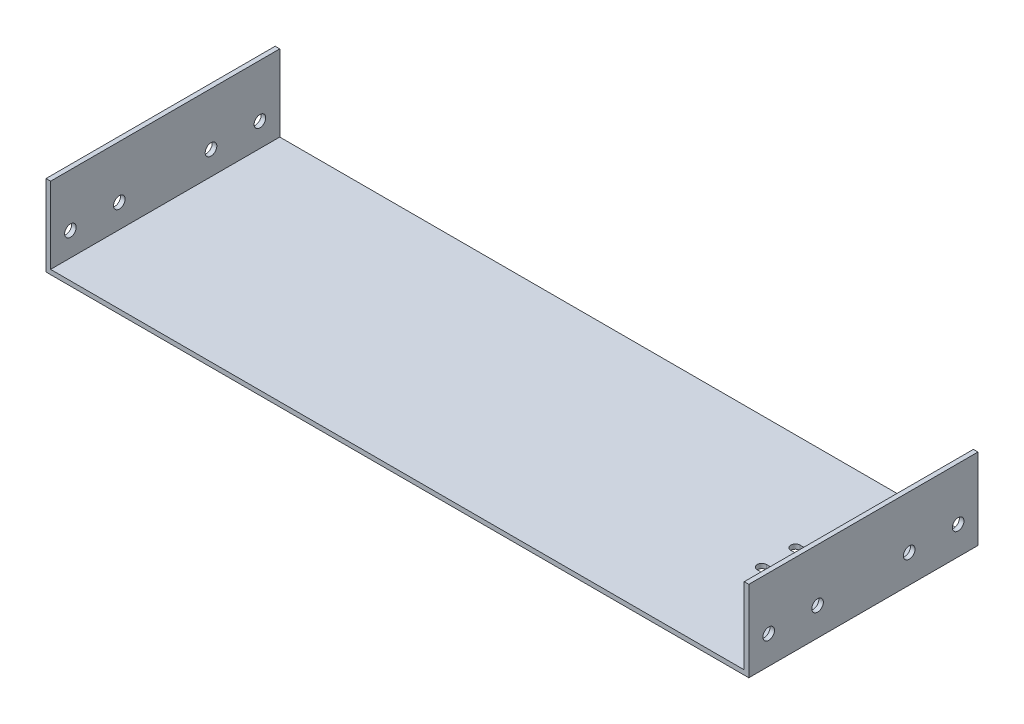
from build123d import *

# Parameters (mm, degrees)
SKETCH1_W               = 460
SKETCH1_H               = 150
BOSS_EXTRUDE1_DEPTH     = 3
SKETCH2_W               = 3
SKETCH2_H               = 150
BOSS_EXTRUDE2_DEPTH     = 50
SKETCH4_R               = 3.8
CUT_EXTRUDE1_DEPTH      = 458
CUT_EXTRUDE1_DEPTH_BACK = 4
CUT_EXTRUDE2_DEPTH      = 10


with BuildPart() as part:
    # Sketch1 → Boss-Extrude1 (new body)
    with BuildSketch(Plane(origin=(0, 0, 0), x_dir=(1, 0, 0), z_dir=(0, 1, 0))):
        Rectangle(SKETCH1_W, SKETCH1_H)
    extrude(amount=BOSS_EXTRUDE1_DEPTH)

    # Sketch2 → Boss-Extrude2 (add)
    with BuildSketch(Plane(origin=(0, 3, 0), x_dir=(1, 0, 0), z_dir=(0, 1, 0))):
        with Locations((-228.5, 0)):
            Rectangle(SKETCH2_W, SKETCH2_H)
        with Locations((228.5, 0)):
            Rectangle(SKETCH2_W, SKETCH2_H)
    extrude(amount=BOSS_EXTRUDE2_DEPTH)

    # Sketch4 → Cut-Extrude1 (cut, two sides)
    with BuildSketch(Plane(origin=(-227, 0, 0), x_dir=(0, 0, -1), z_dir=(1, 0, 0))) as cut_extrude1_sk:
        with Locations((62, 18.5)):
            Circle(SKETCH4_R)
        with Locations((30, 18.5)):
            Circle(SKETCH4_R)
        with Locations((-62, 18.5)):
            Circle(SKETCH4_R)
        with Locations((-30, 18.5)):
            Circle(SKETCH4_R)
    extrude(amount=CUT_EXTRUDE1_DEPTH, mode=Mode.SUBTRACT)
    extrude(cut_extrude1_sk.sketch, amount=-CUT_EXTRUDE1_DEPTH_BACK, mode=Mode.SUBTRACT)

    # Sketch5 → Cut-Extrude2 (cut)
    with BuildSketch(Plane(origin=(0, 3, 0), x_dir=(1, 0, 0), z_dir=(0, 1, 0))):
        with BuildLine():
            ThreePointArc((174.5, -8), (171.5, -11), (174.5, -14))
            Line((174.5, -14), (174.5, -8))
        make_face()
        with BuildLine():
            Line((174.5, -8), (174.5, -14))
            ThreePointArc((174.5, -14), (176.621320344, -13.121320344), (177.5, -11))
            ThreePointArc((177.5, -11), (176.621320344, -8.878679656), (174.5, -8))
        make_face()
        with BuildLine():
            Line((174.5, -14), (204.5, -14))
            ThreePointArc((204.5, -14), (201.5, -11), (204.5, -8))
            Line((204.5, -8), (174.5, -8))
            ThreePointArc((174.5, -8), (176.621320344, -8.878679656), (177.5, -11))
            ThreePointArc((177.5, -11), (176.621320344, -13.121320344), (174.5, -14))
        make_face()
        with BuildLine():
            ThreePointArc((204.5, -8), (201.5, -11), (204.5, -14))
            Line((204.5, -14), (204.5, -8))
        make_face()
        with BuildLine():
            Line((204.5, -8), (204.5, -14))
            ThreePointArc((204.5, -14), (206.621320344, -13.121320344), (207.5, -11))
            ThreePointArc((207.5, -11), (206.621320344, -8.878679656), (204.5, -8))
        make_face()
        with BuildLine():
            ThreePointArc((204.5, 14), (201.5, 11), (204.5, 8))
            Line((204.5, 8), (204.5, 14))
        make_face()
        with BuildLine():
            Line((204.5, 14), (204.5, 8))
            ThreePointArc((204.5, 8), (206.621320344, 8.878679656), (207.5, 11))
            ThreePointArc((207.5, 11), (206.621320344, 13.121320344), (204.5, 14))
        make_face()
        with BuildLine():
            ThreePointArc((177.5, 11), (176.621320344, 8.878679656), (174.5, 8))
            Line((174.5, 8), (204.5, 8))
            ThreePointArc((204.5, 8), (201.5, 11), (204.5, 14))
            Line((204.5, 14), (174.5, 14))
            ThreePointArc((174.5, 14), (176.621320344, 13.121320344), (177.5, 11))
        make_face()
        with BuildLine():
            ThreePointArc((174.5, 14), (171.5, 11), (174.5, 8))
            Line((174.5, 8), (174.5, 14))
        make_face()
        with BuildLine():
            Line((174.5, 14), (174.5, 8))
            ThreePointArc((174.5, 8), (176.621320344, 8.878679656), (177.5, 11))
            ThreePointArc((177.5, 11), (176.621320344, 13.121320344), (174.5, 14))
        make_face()
    extrude(amount=-CUT_EXTRUDE2_DEPTH, mode=Mode.SUBTRACT)


solid = part.part
